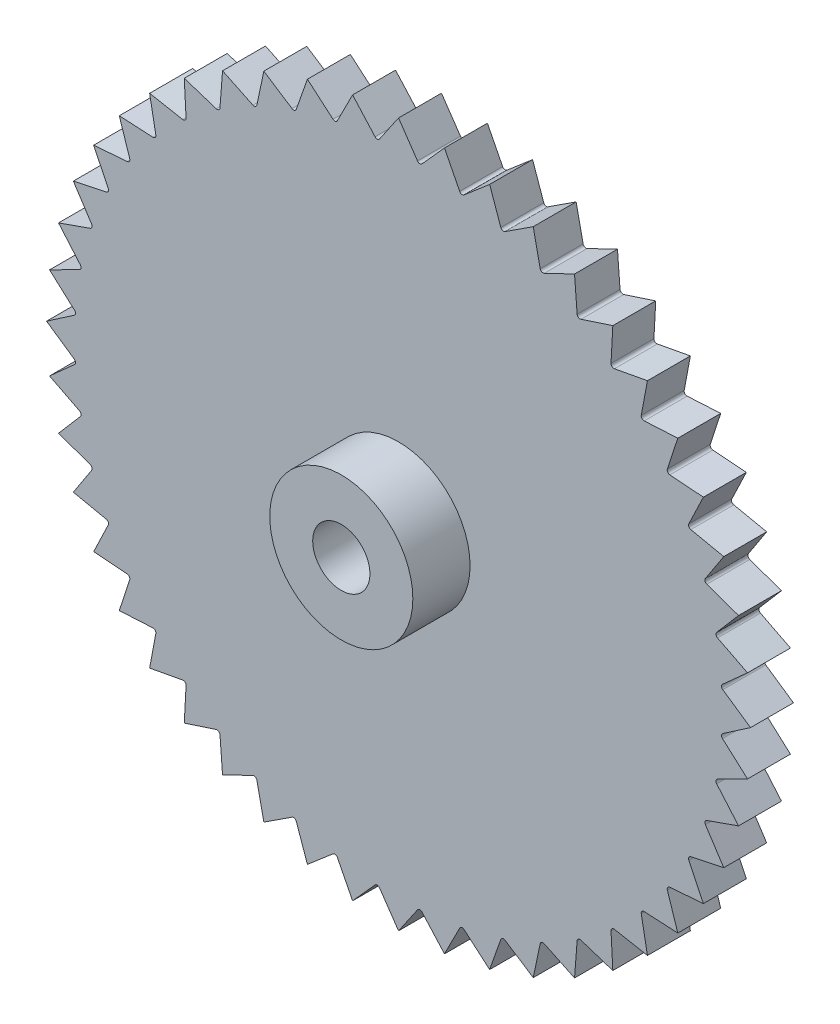
from build123d import *

# Parameters (mm, degrees)
SKETCH1_R           = 12.3
SKETCH1_R_2         = 1
BOSS_EXTRUDE1_DEPTH = 1.5
SKETCH2_R           = 2.5
SKETCH2_R_2         = 1
BOSS_EXTRUDE3_DEPTH = 2
SKETCH3_R           = 2.5
SKETCH3_R_2         = 1
BOSS_EXTRUDE4_DEPTH = 0.5
SKETCH4_R           = 15.294693154
CUT_EXTRUDE1_DEPTH  = 3


with BuildPart() as part:
    # Sketch1 → Boss-Extrude1 (new body)
    with BuildSketch(Plane.XY):
        Circle(SKETCH1_R)
        Circle(SKETCH1_R_2, mode=Mode.SUBTRACT)
    extrude(amount=BOSS_EXTRUDE1_DEPTH)

    # Sketch2 → Boss-Extrude3 (add)
    with BuildSketch(Plane.XY.offset(1.5)):
        Circle(SKETCH2_R)
        Circle(SKETCH2_R_2, mode=Mode.SUBTRACT)
    extrude(amount=BOSS_EXTRUDE3_DEPTH)

    # Sketch3 → Boss-Extrude4 (add)
    with BuildSketch(Plane(origin=(0, 0, 0), x_dir=(-1, 0, 0), z_dir=(0, 0, -1))):
        Circle(SKETCH3_R)
        Circle(SKETCH3_R_2, mode=Mode.SUBTRACT)
    extrude(amount=BOSS_EXTRUDE4_DEPTH)

    # Sketch4 → Cut-Extrude1 (cut, through all)
    with BuildSketch(Plane.XY.offset(1.5)):
        Circle(SKETCH4_R)
        with BuildLine():
            Line((1.605472164, 12.194771795), (2.137169669, 11.147302183))
            ThreePointArc((2.137169669, 11.147302183), (2.20683057, 11.094486477), (2.291400546, 11.116623754))
            Line((2.291400546, 11.116623754), (3.183474255, 11.880887663))
            Line((3.183474255, 11.880887663), (3.573900794, 10.772978848))
            ThreePointArc((3.573900794, 10.772978848), (3.636071903, 10.711522416), (3.722807866, 10.722431709))
            Line((3.722807866, 10.722431709), (4.707006218, 11.36371825))
            Line((4.707006218, 11.36371825), (4.949481485, 10.214326859))
            ThreePointArc((4.949481485, 10.214326859), (5.003099038, 10.145281237), (5.09051691, 10.144775884))
            Line((5.09051691, 10.144775884), (6.15, 10.652112467))
            Line((6.15, 10.652112467), (6.240375176, 9.480904905))
            ThreePointArc((6.240375176, 9.480904905), (6.284521761, 9.405451483), (6.3711258, 9.393540131))
            Line((6.3711258, 9.393540131), (7.487765577, 9.758246086))
            Line((7.487765577, 9.758246086), (7.424494317, 8.585262039))
            ThreePointArc((7.424494317, 8.585262039), (7.458414574, 8.504691846), (7.54272296, 8.481578302))
            Line((7.54272296, 8.481578302), (8.697413409, 8.697413409))
            Line((8.697413409, 8.697413409), (8.481578302, 7.54272296))
            ThreePointArc((8.481578302, 7.54272296), (8.504691846, 7.458414574), (8.585262039, 7.424494317))
            Line((8.585262039, 7.424494317), (9.758246086, 7.487765577))
            Line((9.758246086, 7.487765577), (9.393540131, 6.3711258))
            ThreePointArc((9.393540131, 6.3711258), (9.405451483, 6.284521761), (9.480904905, 6.240375176))
            Line((9.480904905, 6.240375176), (10.652112467, 6.15))
            Line((10.652112467, 6.15), (10.144775884, 5.09051691))
            ThreePointArc((10.144775884, 5.09051691), (10.145281237, 5.003099038), (10.214326859, 4.949481485))
            Line((10.214326859, 4.949481485), (11.36371825, 4.707006218))
            Line((11.36371825, 4.707006218), (10.722431709, 3.722807866))
            ThreePointArc((10.722431709, 3.722807866), (10.711522416, 3.636071903), (10.772978848, 3.573900794))
            Line((10.772978848, 3.573900794), (11.880887663, 3.183474255))
            Line((11.880887663, 3.183474255), (11.116623754, 2.291400546))
            ThreePointArc((11.116623754, 2.291400546), (11.094486477, 2.20683057), (11.147302183, 2.137169669))
            Line((11.147302183, 2.137169669), (12.194771795, 1.605472164))
            Line((12.194771795, 1.605472164), (11.320607285, 0.820786728))
            ThreePointArc((11.320607285, 0.820786728), (11.287620798, 0.739829754), (11.330892086, 0.663870979))
            Line((11.330892086, 0.663870979), (12.3, 0))
            Line((12.3, 0), (11.330892086, -0.663870979))
            ThreePointArc((11.330892086, -0.663870979), (11.287620798, -0.739829754), (11.320607285, -0.820786728))
            Line((11.320607285, -0.820786728), (12.194771795, -1.605472164))
            Line((12.194771795, -1.605472164), (11.147302183, -2.137169669))
            ThreePointArc((11.147302183, -2.137169669), (11.094486477, -2.20683057), (11.116623754, -2.291400546))
            Line((11.116623754, -2.291400546), (11.880887663, -3.183474255))
            Line((11.880887663, -3.183474255), (10.772978848, -3.573900794))
            ThreePointArc((10.772978848, -3.573900794), (10.711522416, -3.636071903), (10.722431709, -3.722807866))
            Line((10.722431709, -3.722807866), (11.36371825, -4.707006218))
            Line((11.36371825, -4.707006218), (10.214326859, -4.949481485))
            ThreePointArc((10.214326859, -4.949481485), (10.145281237, -5.003099038), (10.144775884, -5.09051691))
            Line((10.144775884, -5.09051691), (10.652112467, -6.15))
            Line((10.652112467, -6.15), (9.480904905, -6.240375176))
            ThreePointArc((9.480904905, -6.240375176), (9.405451483, -6.284521761), (9.393540131, -6.3711258))
            Line((9.393540131, -6.3711258), (9.758246086, -7.487765577))
            Line((9.758246086, -7.487765577), (8.585262039, -7.424494317))
            ThreePointArc((8.585262039, -7.424494317), (8.504691846, -7.458414574), (8.481578302, -7.54272296))
            Line((8.481578302, -7.54272296), (8.697413409, -8.697413409))
            Line((8.697413409, -8.697413409), (7.54272296, -8.481578302))
            ThreePointArc((7.54272296, -8.481578302), (7.458414574, -8.504691846), (7.424494317, -8.585262039))
            Line((7.424494317, -8.585262039), (7.487765577, -9.758246086))
            Line((7.487765577, -9.758246086), (6.3711258, -9.393540131))
            ThreePointArc((6.3711258, -9.393540131), (6.284521761, -9.405451483), (6.240375176, -9.480904905))
            Line((6.240375176, -9.480904905), (6.15, -10.652112467))
            Line((6.15, -10.652112467), (5.09051691, -10.144775884))
            ThreePointArc((5.09051691, -10.144775884), (5.003099038, -10.145281237), (4.949481485, -10.214326859))
            Line((4.949481485, -10.214326859), (4.707006218, -11.36371825))
            Line((4.707006218, -11.36371825), (3.722807866, -10.722431709))
            ThreePointArc((3.722807866, -10.722431709), (3.636071903, -10.711522416), (3.573900794, -10.772978848))
            Line((3.573900794, -10.772978848), (3.183474255, -11.880887663))
            Line((3.183474255, -11.880887663), (2.291400546, -11.116623754))
            ThreePointArc((2.291400546, -11.116623754), (2.20683057, -11.094486477), (2.137169669, -11.147302183))
            Line((2.137169669, -11.147302183), (1.605472164, -12.194771795))
            Line((1.605472164, -12.194771795), (0.820786728, -11.320607285))
            ThreePointArc((0.820786728, -11.320607285), (0.739829754, -11.287620798), (0.663870979, -11.330892086))
            Line((0.663870979, -11.330892086), (0, -12.3))
            Line((0, -12.3), (-0.663870979, -11.330892086))
            ThreePointArc((-0.663870979, -11.330892086), (-0.739829754, -11.287620798), (-0.820786728, -11.320607285))
            Line((-0.820786728, -11.320607285), (-1.605472164, -12.194771795))
            Line((-1.605472164, -12.194771795), (-2.137169669, -11.147302183))
            ThreePointArc((-2.137169669, -11.147302183), (-2.20683057, -11.094486477), (-2.291400546, -11.116623754))
            Line((-2.291400546, -11.116623754), (-3.183474255, -11.880887663))
            Line((-3.183474255, -11.880887663), (-3.573900794, -10.772978848))
            ThreePointArc((-3.573900794, -10.772978848), (-3.636071903, -10.711522416), (-3.722807866, -10.722431709))
            Line((-3.722807866, -10.722431709), (-4.707006218, -11.36371825))
            Line((-4.707006218, -11.36371825), (-4.949481485, -10.214326859))
            ThreePointArc((-4.949481485, -10.214326859), (-5.003099038, -10.145281237), (-5.09051691, -10.144775884))
            Line((-5.09051691, -10.144775884), (-6.15, -10.652112467))
            Line((-6.15, -10.652112467), (-6.240375176, -9.480904905))
            ThreePointArc((-6.240375176, -9.480904905), (-6.284521761, -9.405451483), (-6.3711258, -9.393540131))
            Line((-6.3711258, -9.393540131), (-7.487765577, -9.758246086))
            Line((-7.487765577, -9.758246086), (-7.424494317, -8.585262039))
            ThreePointArc((-7.424494317, -8.585262039), (-7.458414574, -8.504691846), (-7.54272296, -8.481578302))
            Line((-7.54272296, -8.481578302), (-8.697413409, -8.697413409))
            Line((-8.697413409, -8.697413409), (-8.481578302, -7.54272296))
            ThreePointArc((-8.481578302, -7.54272296), (-8.504691846, -7.458414574), (-8.585262039, -7.424494317))
            Line((-8.585262039, -7.424494317), (-9.758246086, -7.487765577))
            Line((-9.758246086, -7.487765577), (-9.393540131, -6.3711258))
            ThreePointArc((-9.393540131, -6.3711258), (-9.405451483, -6.284521761), (-9.480904905, -6.240375176))
            Line((-9.480904905, -6.240375176), (-10.652112467, -6.15))
            Line((-10.652112467, -6.15), (-10.144775884, -5.09051691))
            ThreePointArc((-10.144775884, -5.09051691), (-10.145281237, -5.003099038), (-10.214326859, -4.949481485))
            Line((-10.214326859, -4.949481485), (-11.36371825, -4.707006218))
            Line((-11.36371825, -4.707006218), (-10.722431709, -3.722807866))
            ThreePointArc((-10.722431709, -3.722807866), (-10.711522416, -3.636071903), (-10.772978848, -3.573900794))
            Line((-10.772978848, -3.573900794), (-11.880887663, -3.183474255))
            Line((-11.880887663, -3.183474255), (-11.116623754, -2.291400546))
            ThreePointArc((-11.116623754, -2.291400546), (-11.094486477, -2.20683057), (-11.147302183, -2.137169669))
            Line((-11.147302183, -2.137169669), (-12.194771795, -1.605472164))
            Line((-12.194771795, -1.605472164), (-11.320607285, -0.820786728))
            ThreePointArc((-11.320607285, -0.820786728), (-11.287620798, -0.739829754), (-11.330892086, -0.663870979))
            Line((-11.330892086, -0.663870979), (-12.3, 0))
            Line((-12.3, 0), (-11.330892086, 0.663870979))
            ThreePointArc((-11.330892086, 0.663870979), (-11.287620798, 0.739829754), (-11.320607285, 0.820786728))
            Line((-11.320607285, 0.820786728), (-12.194771795, 1.605472164))
            Line((-12.194771795, 1.605472164), (-11.147302183, 2.137169669))
            ThreePointArc((-11.147302183, 2.137169669), (-11.094486477, 2.20683057), (-11.116623754, 2.291400546))
            Line((-11.116623754, 2.291400546), (-11.880887663, 3.183474255))
            Line((-11.880887663, 3.183474255), (-10.772978848, 3.573900794))
            ThreePointArc((-10.772978848, 3.573900794), (-10.711522416, 3.636071903), (-10.722431709, 3.722807866))
            Line((-10.722431709, 3.722807866), (-11.36371825, 4.707006218))
            Line((-11.36371825, 4.707006218), (-10.214326859, 4.949481485))
            ThreePointArc((-10.214326859, 4.949481485), (-10.145281237, 5.003099038), (-10.144775884, 5.09051691))
            Line((-10.144775884, 5.09051691), (-10.652112467, 6.15))
            Line((-10.652112467, 6.15), (-9.480904905, 6.240375176))
            ThreePointArc((-9.480904905, 6.240375176), (-9.405451483, 6.284521761), (-9.393540131, 6.3711258))
            Line((-9.393540131, 6.3711258), (-9.758246086, 7.487765577))
            Line((-9.758246086, 7.487765577), (-8.585262039, 7.424494317))
            ThreePointArc((-8.585262039, 7.424494317), (-8.504691846, 7.458414574), (-8.481578302, 7.54272296))
            Line((-8.481578302, 7.54272296), (-8.697413409, 8.697413409))
            Line((-8.697413409, 8.697413409), (-7.54272296, 8.481578302))
            ThreePointArc((-7.54272296, 8.481578302), (-7.458414574, 8.504691846), (-7.424494317, 8.585262039))
            Line((-7.424494317, 8.585262039), (-7.487765577, 9.758246086))
            Line((-7.487765577, 9.758246086), (-6.3711258, 9.393540131))
            ThreePointArc((-6.3711258, 9.393540131), (-6.284521761, 9.405451483), (-6.240375176, 9.480904905))
            Line((-6.240375176, 9.480904905), (-6.15, 10.652112467))
            Line((-6.15, 10.652112467), (-5.09051691, 10.144775884))
            ThreePointArc((-5.09051691, 10.144775884), (-5.003099038, 10.145281237), (-4.949481485, 10.214326859))
            Line((-4.949481485, 10.214326859), (-4.707006218, 11.36371825))
            Line((-4.707006218, 11.36371825), (-3.722807866, 10.722431709))
            ThreePointArc((-3.722807866, 10.722431709), (-3.636071903, 10.711522416), (-3.573900794, 10.772978848))
            Line((-3.573900794, 10.772978848), (-3.183474255, 11.880887663))
            Line((-3.183474255, 11.880887663), (-2.291400546, 11.116623754))
            ThreePointArc((-2.291400546, 11.116623754), (-2.20683057, 11.094486477), (-2.137169669, 11.147302183))
            Line((-2.137169669, 11.147302183), (-1.605472164, 12.194771795))
            Line((-1.605472164, 12.194771795), (-0.820786728, 11.320607285))
            ThreePointArc((-0.820786728, 11.320607285), (-0.739829754, 11.287620798), (-0.663870979, 11.330892086))
            Line((-0.663870979, 11.330892086), (0, 12.3))
            Line((0, 12.3), (0.663870979, 11.330892086))
            ThreePointArc((0.663870979, 11.330892086), (0.739829754, 11.287620798), (0.820786728, 11.320607285))
            Line((0.820786728, 11.320607285), (1.605472164, 12.194771795))
        make_face(mode=Mode.SUBTRACT)
    extrude(amount=-CUT_EXTRUDE1_DEPTH, mode=Mode.SUBTRACT)


solid = part.part
